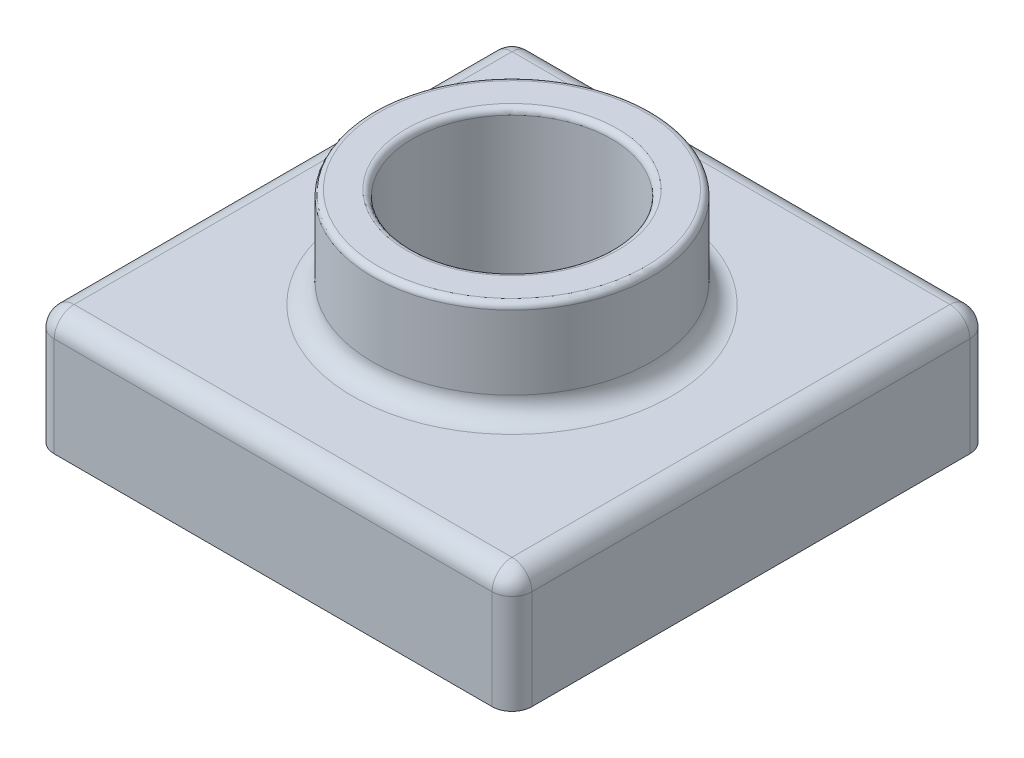
from build123d import *

# Parameters (mm, degrees)
SKETCH2_W               = 120
SKETCH2_H               = 120
BOSS_EXTRUDE1_DEPTH     = 30
SKETCH4_R               = 35
BOSS_EXTRUDE2_DEPTH     = 25
SKETCH5_R               = 25
CUT_EXTRUDE1_DEPTH      = 179.395627749
CUT_EXTRUDE1_DEPTH_BACK = 179.395627749
FILLET1_R               = 5
FILLET2_R               = 1.5
SHELL1_T                = -2


with BuildPart() as part:
    # Sketch2 → Boss-Extrude1 (new body)
    with BuildSketch(Plane(origin=(0, 0, 0), x_dir=(1, 0, 0), z_dir=(0, 1, 0))):
        with Locations((60, 60)):
            Rectangle(SKETCH2_W, SKETCH2_H)
    extrude(amount=BOSS_EXTRUDE1_DEPTH)

    # Sketch4 → Boss-Extrude2 (add)
    with BuildSketch(Plane(origin=(0, 30, 0), x_dir=(1, 0, 0), z_dir=(0, 1, 0))):
        with Locations(Location((60, 60, 0), (0, 0, 270))):
            Circle(SKETCH4_R)
    extrude(amount=BOSS_EXTRUDE2_DEPTH)

    # Sketch5 → Cut-Extrude1 (cut, two sides)
    with BuildSketch(Plane(origin=(0, 55, 0), x_dir=(1, 0, 0), z_dir=(0, 1, 0))) as cut_extrude1_sk:
        with Locations(Location((60, 60, 0), (0, 0, 270))):
            Circle(SKETCH5_R)
    extrude(amount=CUT_EXTRUDE1_DEPTH, mode=Mode.SUBTRACT)
    extrude(cut_extrude1_sk.sketch, amount=-CUT_EXTRUDE1_DEPTH_BACK, mode=Mode.SUBTRACT)

    # Fillet1
    fillet1_edges = [part.edges().sort_by_distance(p)[0] for p in [
        (120, 30, -60),
        (60, 30, -95),
        (60, 30, -120),
        (0, 30, -60),
        (0, 15, -120),
        (120, 15, -120),
        (120, 15, 0),
        (0, 15, 0),
        (60, 30, 0),
    ]]
    fillet(fillet1_edges, radius=FILLET1_R)

    # Fillet2
    fillet2_edges = [part.edges().sort_by_distance(p)[0] for p in [
        (60, 55, -95),
        (60, 55, -85),
    ]]
    fillet(fillet2_edges, radius=FILLET2_R)

    # Shell1
    shell1_openings = [part.faces().sort_by_distance(p)[0] for p in [
        (60, 0, -1.697056275),
    ]]
    offset(amount=SHELL1_T, openings=shell1_openings, kind=Kind.INTERSECTION)


solid = part.part
